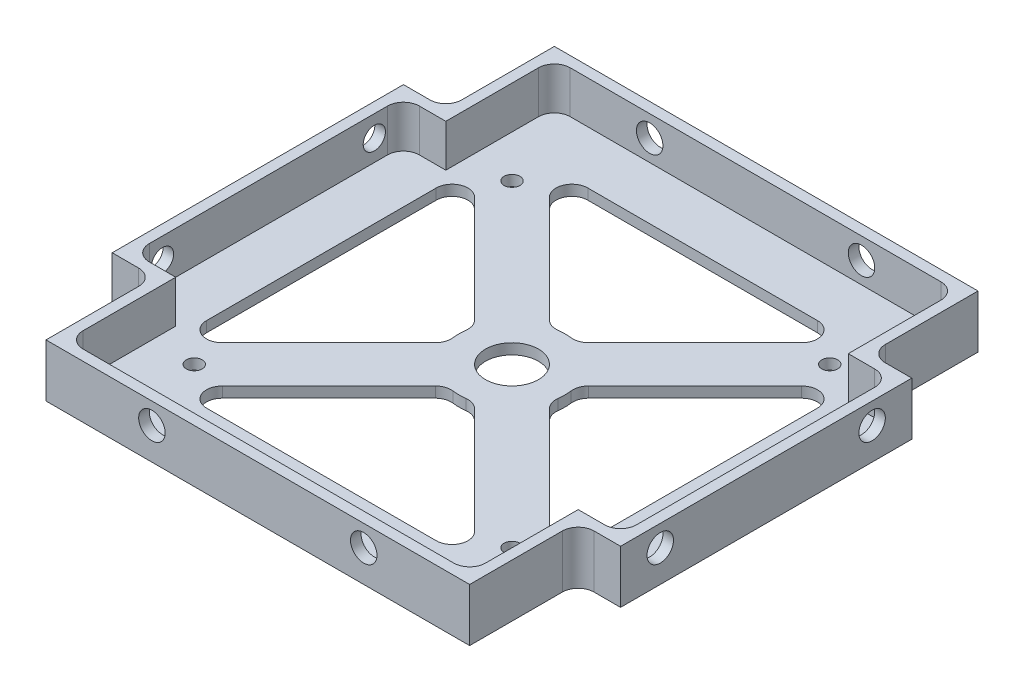
from build123d import *

# Parameters (mm, degrees)
BOSS_EXTRUDE1_DEPTH             = 10
SKETCH2_R                       = 5
CUT_EXTRUDE1_DEPTH              = 11
FILLET1_R                       = 3
CUT_EXTRUDE4_DEPTH              = 11
CUT_EXTRUDE5_DEPTH              = 8
FILLET2_R                       = 3
F_5_0MM_DOWEL_HOLE2_AT_2_COUNT  = 2
F_5_0MM_DOWEL_HOLE2_AT_2_PITCH  = 40
TAP_DRILL_FOR_M5X0_8_TAP1_D     = 4.2
TAP_DRILL_FOR_M5X0_8_TAP1_DEPTH = 2
F_3_0MM_DOWEL_HOLE3_D           = 3
F_5_0MM_DOWEL_HOLE1_D           = 5
F_5_0MM_DOWEL_HOLE1_DEPTH       = 2


with BuildPart() as part:
    # Sketch1 → Boss-Extrude1 (new body)
    with BuildSketch(Plane(origin=(0, 0, 0), x_dir=(1, 0, 0), z_dir=(0, 1, 0))):
        Polygon((0, 88), (0, 8), (8, 0), (88, 0), (96, 8), (96, 88), (88, 96), (8, 96), align=None)
    extrude(amount=BOSS_EXTRUDE1_DEPTH)

    # Sketch2 → Cut-Extrude1 (cut, through all)
    with BuildSketch(Plane(origin=(0, 0, 0), x_dir=(-1, 0, 0), z_dir=(0, -1, 0))):
        with BuildLine():
            Line((-45.411809549, 57.659258263), (-19.071067812, 84))
            Line((-19.071067812, 84), (-76.928932188, 84))
            Line((-76.928932188, 84), (-50.588190451, 57.659258263))
            ThreePointArc((-50.588190451, 57.659258263), (-48, 58), (-45.411809549, 57.659258263))
        make_face()
        with BuildLine():
            Line((-12, 76.928932188), (-38.340741737, 50.588190451))
            ThreePointArc((-38.340741737, 50.588190451), (-38.085551386, 49.305261922), (-38, 48))
            ThreePointArc((-38, 48), (-38.085551386, 46.694738078), (-38.340741737, 45.411809549))
            Line((-38.340741737, 45.411809549), (-12, 19.071067812))
            Line((-12, 19.071067812), (-12, 76.928932188))
        make_face()
        with BuildLine():
            Line((-19.071067812, 12), (-45.411809549, 38.340741737))
            ThreePointArc((-45.411809549, 38.340741737), (-48, 38), (-50.588190451, 38.340741737))
            Line((-50.588190451, 38.340741737), (-76.928932188, 12))
            Line((-76.928932188, 12), (-19.071067812, 12))
        make_face()
        with BuildLine():
            ThreePointArc((-57.659258263, 45.411809549), (-58, 48), (-57.659258263, 50.588190451))
            Line((-57.659258263, 50.588190451), (-84, 76.928932188))
            Line((-84, 76.928932188), (-84, 19.071067812))
            Line((-84, 19.071067812), (-57.659258263, 45.411809549))
        make_face()
        with Locations((-48, 48)):
            Circle(SKETCH2_R)
    extrude(amount=-CUT_EXTRUDE1_DEPTH, mode=Mode.SUBTRACT)

    # Fillet1
    fillet1_edges = [part.edges().sort_by_distance(p)[0] for p in [
        (50.588190451, 5, -38.340741737),
        (45.411809549, 5, -38.340741737),
        (19.071067812, 5, -12),
        (76.928932188, 5, -12),
        (38.340741737, 5, -45.411809549),
        (38.340741737, 5, -50.588190451),
        (12, 5, -76.928932188),
        (12, 5, -19.071067812),
        (57.659258263, 5, -50.588190451),
        (57.659258263, 5, -45.411809549),
        (84, 5, -19.071067812),
        (84, 5, -76.928932188),
        (45.411809549, 5, -57.659258263),
        (50.588190451, 5, -57.659258263),
        (76.928932188, 5, -84),
        (19.071067812, 5, -84),
    ]]
    fillet(fillet1_edges, radius=FILLET1_R)

    # Sketch5 → Cut-Extrude4 (cut, through all)
    with BuildSketch(Plane(origin=(0, 10, 0), x_dir=(1, 0, 0), z_dir=(0, 1, 0))):
        Polygon((8, 0), (8, 20.5), (0, 20.5), (0, 8), align=None)
        Polygon((96, 8), (88, 0), (88, 20.5), (96, 20.5), align=None)
        Polygon((96, 75.5), (88, 75.5), (88, 96), (96, 88), align=None)
        Polygon((8, 96), (8, 75.5), (0, 75.5), (0, 88), align=None)
    extrude(amount=-CUT_EXTRUDE4_DEPTH, mode=Mode.SUBTRACT)

    # Sketch6 → Cut-Extrude5 (cut)
    with BuildSketch(Plane(origin=(0, 10, 0), x_dir=(1, 0, 0), z_dir=(0, 1, 0))):
        Polygon((86, 73.5), (86, 94), (10, 94), (10, 73.5), (2, 73.5), (2, 22.5), (10, 22.5), (10, 2), (86, 2), (86, 22.5), (94, 22.5), (94, 73.5), align=None)
    extrude(amount=-CUT_EXTRUDE5_DEPTH, mode=Mode.SUBTRACT)

    # Fillet2
    fillet2_edges = [part.edges().sort_by_distance(p)[0] for p in [
        (8, 5, -75.5),
        (88, 5, -75.5),
        (88, 5, -20.5),
        (8, 5, -20.5),
        (94, 6, -73.5),
        (94, 6, -22.5),
        (86, 6, -2),
        (10, 6, -2),
        (2, 6, -22.5),
        (2, 6, -73.5),
        (10, 6, -94),
        (86, 6, -94),
    ]]
    fillet(fillet2_edges, radius=FILLET2_R)

    # Sketch13 → Ø5.0mm Dowel Hole2 (revolve, cut)
    with BuildSketch(Plane(origin=(28, 6, 0), x_dir=(0, -1, 0), z_dir=(1, 0, 0))):
        Polygon((0, 0), (0, 9.002151548), (2.5, 7.5), (2.5, 0), align=None)
    f_5_0mm_dowel_hole2 = revolve(axis=Axis((28, 6, 6.35), (0, 0, -1)), mode=Mode.SUBTRACT)

    # Ø5.0mm Dowel Hole2 at 2: Ø5.0mm Dowel Hole2 ×2
    with Locations(*[(i * F_5_0MM_DOWEL_HOLE2_AT_2_PITCH, 0, 0) for i in range(1, F_5_0MM_DOWEL_HOLE2_AT_2_COUNT)]):
        add(f_5_0mm_dowel_hole2, mode=Mode.SUBTRACT)

    # Tap Drill for M5x0.8 Tap1
    with Locations(Plane.ZY):
        with Locations((-68, 6), (-28, 6)):
            Hole(TAP_DRILL_FOR_M5X0_8_TAP1_D / 2, depth=TAP_DRILL_FOR_M5X0_8_TAP1_DEPTH)

    # Mirror1: Ø5.0mm Dowel Hole2 across plane
    add(f_5_0mm_dowel_hole2.mirror(Plane.XY.offset(-48)), mode=Mode.SUBTRACT)

    # Mirror1 copy 1 sketch → Mirror1 copy 1 (revolve, cut)
    with BuildSketch(Plane(origin=(68, 6, -96), x_dir=(0, -1, 0), z_dir=(1, 0, 0))):
        Polygon((0, 0), (0, -9.002151548), (2.5, -7.5), (2.5, 0), align=None)
    revolve(axis=Axis((68, 6, -102.35), (0, 0, -1)), mode=Mode.SUBTRACT)

    # Ø3.0mm Dowel Hole3 (through all)
    with Locations(Plane(origin=(78, 0, -18), x_dir=(0, 0, -1), z_dir=(0, -1, 0))):
        with Locations((0, 0), (60, 0), (60, -60), (0, -60)):
            Hole(F_3_0MM_DOWEL_HOLE3_D / 2)

    # Ø5.0mm Dowel Hole1
    with Locations(Plane(origin=(96, 6, -68), x_dir=(0, 0, 1), z_dir=(1, 0, 0))):
        with Locations((0, 0), (40, 0)):
            Hole(F_5_0MM_DOWEL_HOLE1_D / 2, depth=F_5_0MM_DOWEL_HOLE1_DEPTH)


solid = part.part
